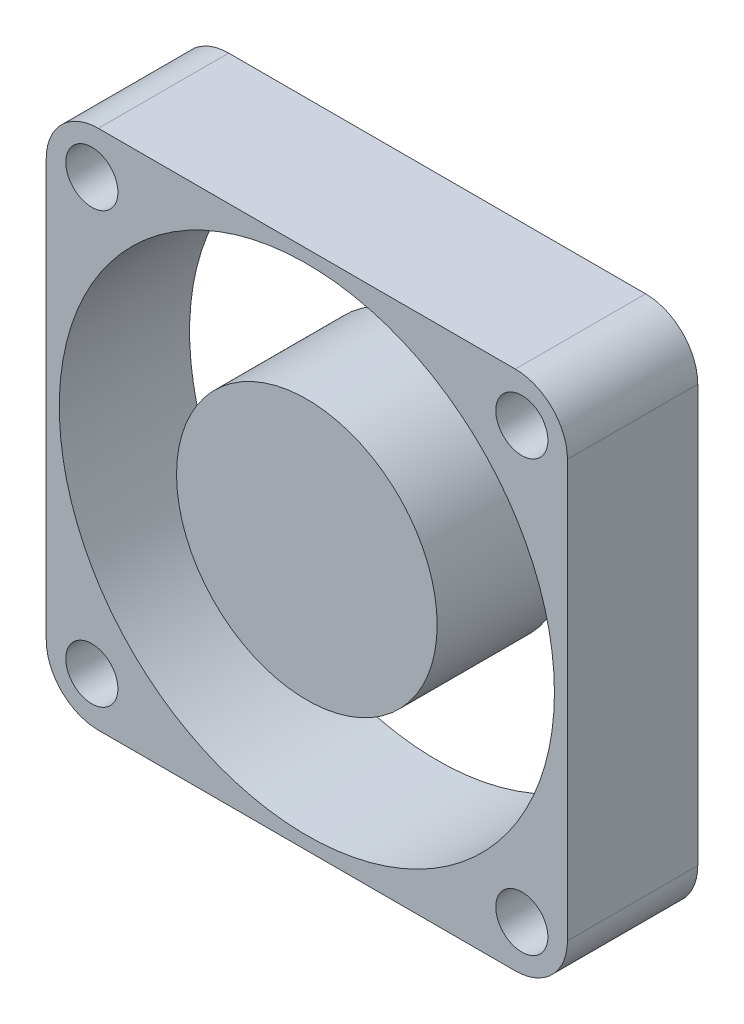
from build123d import *

# Parameters (mm, degrees)
SKETCH1_W             = 40
SKETCH1_H             = 40
SKETCH1_R             = 2
SKETCH1_R_2           = 19
BOSS_EXTRUDE1_DEPTH   = 10
SKETCH1_R_3           = 10
BOSS_EXTRUDE1_2_DEPTH = 10
FILLET1_R             = 4


with BuildPart() as part:
    # Sketch1 → Boss-Extrude1 (new body)
    with BuildSketch(Plane.XY):
        with Locations((20, 20)):
            Rectangle(SKETCH1_W, SKETCH1_H)
        with Locations((3.5, 36.5)):
            Circle(SKETCH1_R, mode=Mode.SUBTRACT)
        with Locations((3.5, 3.5)):
            Circle(SKETCH1_R, mode=Mode.SUBTRACT)
        with Locations((36.5, 3.5)):
            Circle(SKETCH1_R, mode=Mode.SUBTRACT)
        with Locations((36.5, 36.5)):
            Circle(SKETCH1_R, mode=Mode.SUBTRACT)
        with Locations((20, 20)):
            Circle(SKETCH1_R_2, mode=Mode.SUBTRACT)
    extrude(amount=BOSS_EXTRUDE1_DEPTH)

    # Fillet1
    fillet1_edges = [part.edges().sort_by_distance(p)[0] for p in [
        (0, 0, 5),
        (0, 40, 5),
        (40, 40, 5),
        (40, 0, 5),
    ]]
    fillet(fillet1_edges, radius=FILLET1_R)


with BuildPart() as body_2:
    # Sketch1 → Boss-Extrude1 2 (new body)
    with BuildSketch(Plane.XY):
        with Locations((20, 20)):
            Circle(SKETCH1_R_3)
    extrude(amount=BOSS_EXTRUDE1_2_DEPTH)


solid = Compound([part.part, body_2.part])
